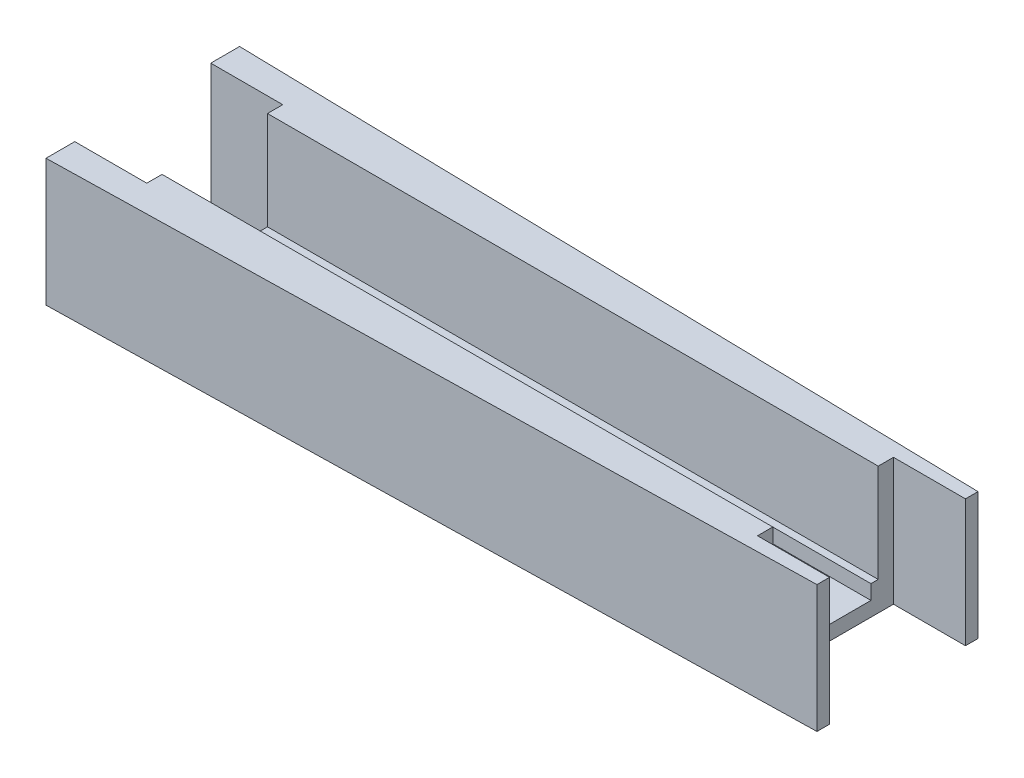
from build123d import *

# Parameters (mm, degrees)
BOSS_EXTRUDE1_DEPTH     = 17.5
SKETCH2_W               = 252
SKETCH2_H               = 14.5
CUT_EXTRUDE1_DEPTH      = 15.5
SKETCH3_R               = 13
CUT_EXTRUDE2_DEPTH      = 15.5
CUT_EXTRUDE3_REACH      = 264.265
CUT_EXTRUDE3_END_RADIUS = 13
SKETCH5_W               = 252
SKETCH5_H               = 1
BOSS_EXTRUDE2_DEPTH     = 2
SKETCH6_R               = 1
CUT_EXTRUDE4_DEPTH      = 2
CUT_EXTRUDE9_DEPTH      = 278.209870862


with BuildPart() as part:
    # Sketch1 → Boss-Extrude1 (new body)
    with BuildSketch(Plane(origin=(0, 0, 0), x_dir=(1, 0, 0), z_dir=(0, 1, 0))):
        with BuildLine():
            Line((0.323033708, 14.996521237), (267.19920412, 9.247854763))
            ThreePointArc((267.19920412, 9.247854763), (276.25, 0), (267.19920412, -9.247854763))
            Line((267.19920412, -9.247854763), (0.323033708, -14.996521237))
            ThreePointArc((0.323033708, -14.996521237), (-15, 0), (0.323033708, 14.996521237))
        make_face()
    extrude(amount=BOSS_EXTRUDE1_DEPTH)

    # Sketch2 → Cut-Extrude1 (cut)
    with BuildSketch(Plane(origin=(0, 17.5, 0), x_dir=(1, 0, 0), z_dir=(0, 1, 0))):
        with Locations((141, 0)):
            Rectangle(SKETCH2_W, SKETCH2_H)
    extrude(amount=-CUT_EXTRUDE1_DEPTH, mode=Mode.SUBTRACT)

    # Sketch3 → Cut-Extrude2 (cut)
    with BuildSketch(Plane(origin=(0, 17.5, 0), x_dir=(1, 0, 0), z_dir=(0, 1, 0))):
        with Locations(Location((0, 0, 0), (0, 0, 270))):
            Circle(SKETCH3_R)
    extrude(amount=-CUT_EXTRUDE2_DEPTH, mode=Mode.SUBTRACT)

    # Cut-Extrude3: up to this cylinder (the profile starts outside it)
    cut_extrude3_end = Plane(origin=(0, 8.125709, 0), z_dir=(0, 1, 0)) * Cylinder(CUT_EXTRUDE3_END_RADIUS, 555.53, mode=Mode.PRIVATE)
    # Sketch4 → Cut-Extrude3 (cut, up to the surface)
    with BuildSketch(Plane(origin=(15, 0, 0), x_dir=(0, 0, -1), z_dir=(1, 0, 0)), mode=Mode.PRIVATE) as cut_extrude3_sk1:
        with BuildLine():
            Line((-7.25, 2), (7.25, 2))
            Line((7.25, 2), (7.25, 8.5))
            ThreePointArc((7.25, 8.5), (5.199747468, 13.449747468), (0.25, 15.5))
            Line((0.25, 15.5), (-0.25, 15.5))
            ThreePointArc((-0.25, 15.5), (-5.199747468, 13.449747468), (-7.25, 8.5))
            Line((-7.25, 8.5), (-7.25, 2))
        make_face()
    cut_extrude3_tool1 = extrude(cut_extrude3_sk1.sketch, amount=-CUT_EXTRUDE3_REACH, mode=Mode.PRIVATE) - cut_extrude3_end
    add(cut_extrude3_tool1.solids().sort_by_distance((15, 8.125709, 0))[0], mode=Mode.SUBTRACT)

    # Sketch5 → Boss-Extrude2 (add)
    with BuildSketch(Plane(origin=(0, 2, 0), x_dir=(1, 0, 0), z_dir=(0, 1, 0))):
        with Locations((141, 6.75)):
            Rectangle(SKETCH5_W, SKETCH5_H)
        with Locations((141, -6.75)):
            Rectangle(SKETCH5_W, SKETCH5_H)
    extrude(amount=BOSS_EXTRUDE2_DEPTH)

    # Sketch6 → Cut-Extrude4 (cut)
    with BuildSketch(Plane(origin=(0, 2, 0), x_dir=(1, 0, 0), z_dir=(0, 1, 0))):
        with Locations(Location((-5.25, 9.09326674, 0), (0, 0, 270))):
            Circle(SKETCH6_R)
        with Locations(Location((-10.5, 0, 0), (0, 0, 270))):
            Circle(SKETCH6_R)
        with Locations(Location((5.25, 9.09326674, 0), (0, 0, 270))):
            Circle(SKETCH6_R)
        with Locations(Location((10.5, 0, 0), (0, 0, 270))):
            Circle(SKETCH6_R)
        with Locations(Location((5.25, -9.09326674, 0), (0, 0, 270))):
            Circle(SKETCH6_R)
        with Locations(Location((-5.25, -9.09326674, 0), (0, 0, 270))):
            Circle(SKETCH6_R)
        Polygon((0, -10), (8.660254038, -5), (8.660254038, 5), (0, 10), (-8.660254038, 5), (-8.660254038, -5), align=None)
    extrude(amount=-CUT_EXTRUDE4_DEPTH, mode=Mode.SUBTRACT)

    # Sketch14 → Cut-Extrude9 (cut, through all)
    with BuildSketch(Plane(origin=(0, 0, 0), x_dir=(1, 0, 0), z_dir=(0, 1, 0))):
        Polygon((88.5, 9.35), (78.6, 9.35), (78.6, 35), (78.4, 35), (78.4, 9.15), (88.3, 9.15), (88.3, -9.15), (78.4, -9.15), (78.4, -35), (78.6, -35), (78.6, -9.35), (88.5, -9.35), align=None)
        Polygon((172.7, 9.15), (182.6, 9.15), (182.6, 35), (182.4, 35), (182.4, 9.35), (172.5, 9.35), (172.5, 9.25), (172.5, -9.35), (182.4, -9.35), (182.4, -35), (182.6, -35), (182.6, -9.15), (172.7, -9.15), align=None)
    extrude(amount=CUT_EXTRUDE9_DEPTH, mode=Mode.SUBTRACT)


with BuildPart() as cut_extrude9_kept_piece:
    # of the separate pieces the step leaves, the one the design keeps (cut_extrude9_pieces_kept)
    add(part.part.solids().sort_by_distance((182.4, 0, 11.074478478))[0])


solid = cut_extrude9_kept_piece.part
